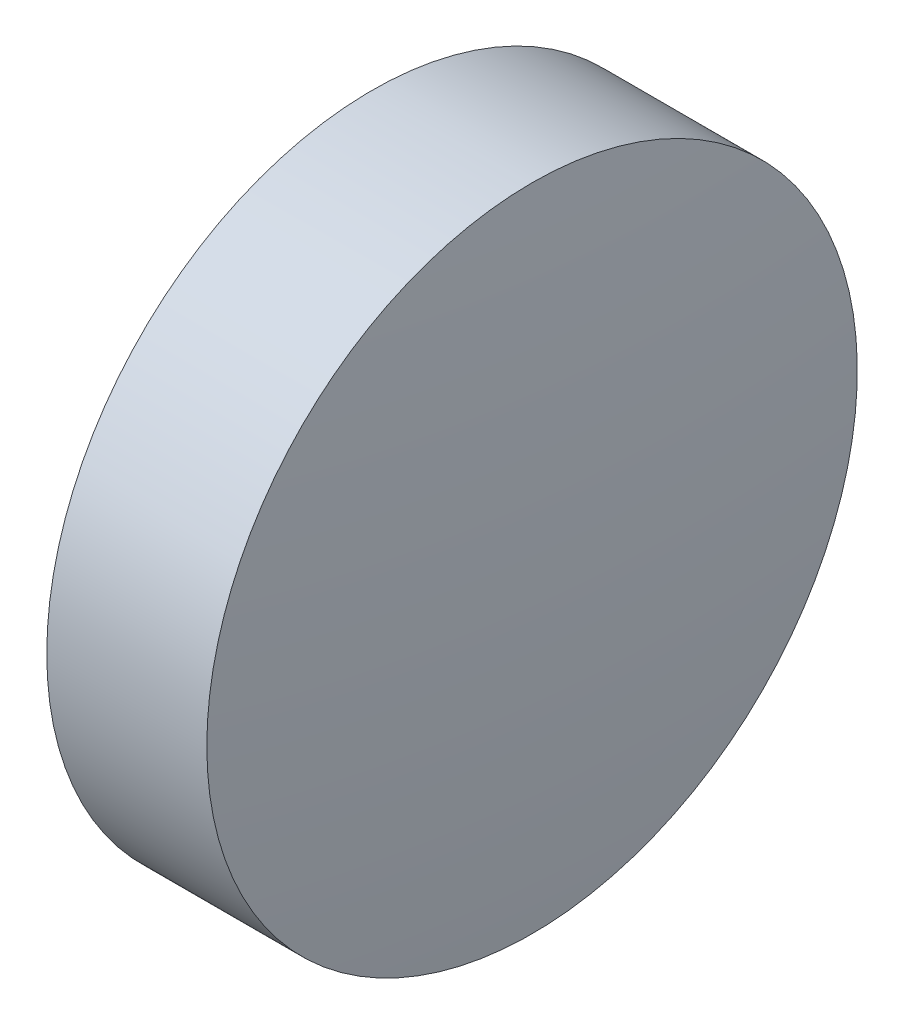
from build123d import *


with BuildPart() as part:
    # 草图2 → 旋转1 (revolve)
    with BuildSketch(Plane.XY):
        with BuildLine():
            Line((1116.761526673, 408.864306222), (1116.761526673, 412.014306222))
            Line((1116.761526673, 412.014306222), (1118.311526673, 412.014306222))
            ThreePointArc((1118.311526673, 412.014306222), (1118.424005439, 410.441090925), (1118.461526673, 408.864306222))
            Line((1118.461526673, 408.864306222), (1116.761526673, 408.864306222))
        make_face()
    revolve(axis=Axis((1116.27186869, 408.864306222, 0), (1, 0, 0)))


solid = part.part
